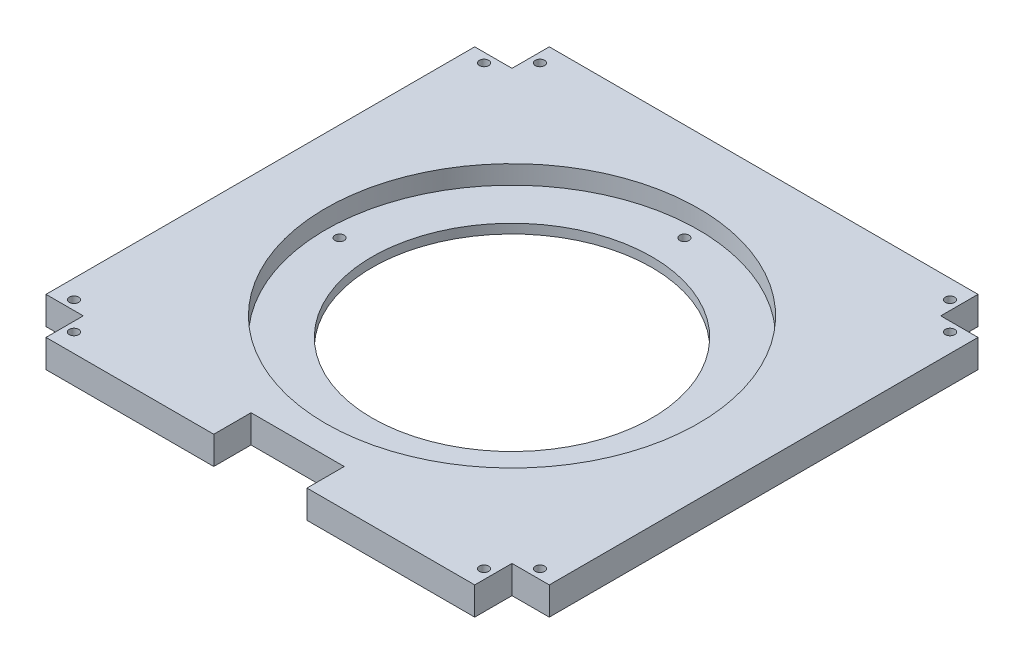
from build123d import *

# Parameters (mm, degrees)
SKETCH1_W           = 270
SKETCH1_H           = 270
BOSS_EXTRUDE1_DEPTH = 15
SKETCH8_W           = 20
SKETCH8_H           = 20
CUT_EXTRUDE1_DEPTH  = 16
SKETCH9_R           = 2.5
CUT_EXTRUDE2_DEPTH  = 16
SKETCH10_R          = 100
CUT_EXTRUDE3_DEPTH  = 10
SKETCH12_R          = 75
SKETCH12_R_2        = 2.5
CUT_EXTRUDE4_DEPTH  = 6
SKETCH13_W          = 50
SKETCH13_H          = 20
CUT_EXTRUDE5_DEPTH  = 15


with BuildPart() as part:
    # Sketch1 → Boss-Extrude1 (new body)
    with BuildSketch(Plane(origin=(0, 0, 0), x_dir=(1, 0, 0), z_dir=(0, 1, 0))):
        with Locations((135, 135)):
            Rectangle(SKETCH1_W, SKETCH1_H)
    extrude(amount=BOSS_EXTRUDE1_DEPTH)

    # Sketch8 → Cut-Extrude1 (cut, through all)
    with BuildSketch(Plane(origin=(0, 15, 0), x_dir=(1, 0, 0), z_dir=(0, 1, 0))):
        with Locations((10, 260)):
            Rectangle(SKETCH8_W, SKETCH8_H)
        with Locations((260, 260)):
            Rectangle(SKETCH8_W, SKETCH8_H)
        with Locations((260, 10)):
            Rectangle(SKETCH8_W, SKETCH8_H)
        with Locations((10, 10)):
            Rectangle(SKETCH8_W, SKETCH8_H)
    extrude(amount=-CUT_EXTRUDE1_DEPTH, mode=Mode.SUBTRACT)

    # Sketch9 → Cut-Extrude2 (cut, through all)
    with BuildSketch(Plane(origin=(0, 15, 0), x_dir=(1, 0, 0), z_dir=(0, 1, 0))):
        with Locations((10, 245)):
            Circle(SKETCH9_R)
        with Locations((10, 25)):
            Circle(SKETCH9_R)
        with Locations((25, 10)):
            Circle(SKETCH9_R)
        with Locations((245, 10)):
            Circle(SKETCH9_R)
        with Locations((260, 25)):
            Circle(SKETCH9_R)
        with Locations((260, 245)):
            Circle(SKETCH9_R)
        with Locations((245, 260)):
            Circle(SKETCH9_R)
        with Locations((25, 260)):
            Circle(SKETCH9_R)
    extrude(amount=-CUT_EXTRUDE2_DEPTH, mode=Mode.SUBTRACT)

    # Sketch10 → Cut-Extrude3 (cut)
    with BuildSketch(Plane(origin=(0, 15, 0), x_dir=(1, 0, 0), z_dir=(0, 1, 0))):
        with Locations((135, 135)):
            Circle(SKETCH10_R)
    extrude(amount=-CUT_EXTRUDE3_DEPTH, mode=Mode.SUBTRACT)

    # Sketch12 → Cut-Extrude4 (cut, through all)
    with BuildSketch(Plane(origin=(0, 5, 0), x_dir=(1, 0, 0), z_dir=(0, 1, 0))):
        with Locations((135, 135)):
            Circle(SKETCH12_R)
        with Locations((135, 227.5)):
            Circle(SKETCH12_R_2)
        with Locations((227.5, 135)):
            Circle(SKETCH12_R_2)
        with Locations((135, 42.5)):
            Circle(SKETCH12_R_2)
        with Locations((42.5, 135)):
            Circle(SKETCH12_R_2)
    extrude(amount=-CUT_EXTRUDE4_DEPTH, mode=Mode.SUBTRACT)

    # Sketch13 → Cut-Extrude5 (cut)
    with BuildSketch(Plane(origin=(0, 15, 0), x_dir=(1, 0, 0), z_dir=(0, 1, 0))):
        with Locations((135, 10)):
            Rectangle(SKETCH13_W, SKETCH13_H)
    extrude(amount=-CUT_EXTRUDE5_DEPTH, mode=Mode.SUBTRACT)


solid = part.part
